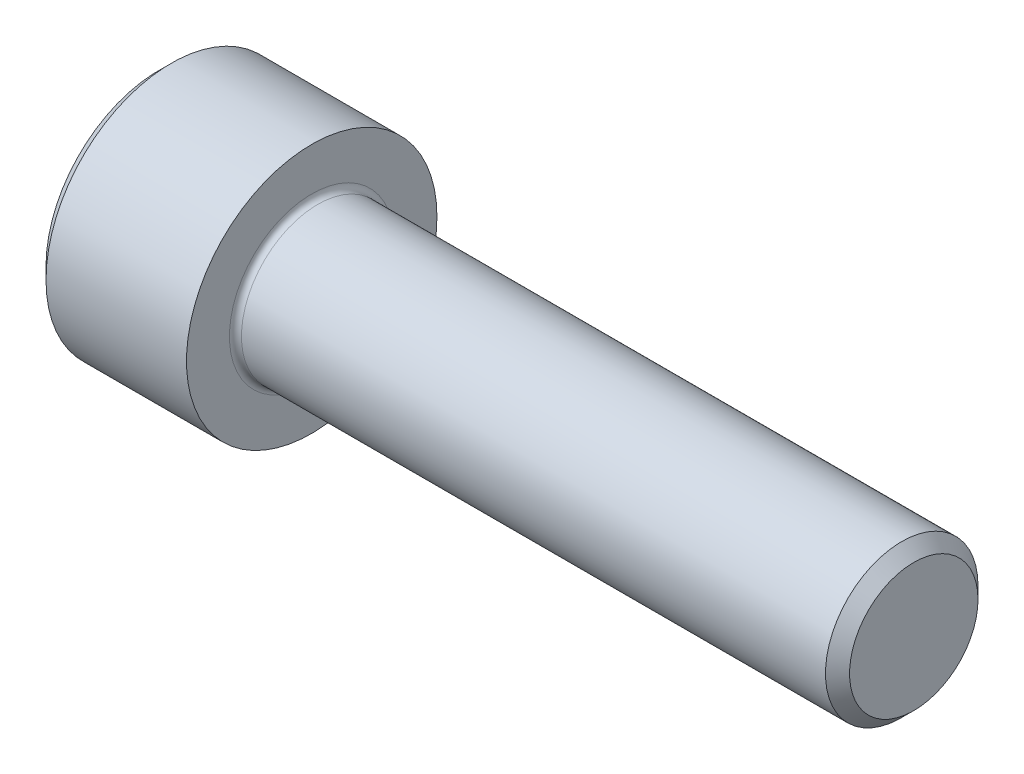
from build123d import *

# Parameters (mm, degrees)
HEX_START         = -3.217333
HEX_2_DEPTH       = 3.217333
CHAMFER1_SIZE     = 0.381
FILLET1_R         = 0.1905
SKETCH3_R         = 2.291358881
HEX_CHAMFER_DEPTH = 2.54
HEX_CHAMFER_DRAFT = 45


with BuildPart() as part:
    # Sketch1 → Body (revolve)
    with BuildSketch(Plane(origin=(0, 0, 0), x_dir=(1, 0, 0), z_dir=(0, 1, 0))):
        Polygon((0, 0), (0, 3.9624), (4.826, 3.9624), (4.826, 2.413), (23.876, 2.413), (23.876, 0), align=None)
    revolve(axis=Axis((23.876, 0, 0), (-1, 0, 0)))

    # Sketch2 → Hex 2 (cut)
    with BuildSketch(Plane.ZY.offset(HEX_START)):
        Polygon((-2.291358881, 0), (-1.14567944, -1.984375), (1.14567944, -1.984375), (2.291358881, 0), (1.14567944, 1.984375), (-1.14567944, 1.984375), align=None)
    extrude(amount=HEX_2_DEPTH, mode=Mode.SUBTRACT)

    # Chamfer1
    chamfer1_edges = [part.edges().sort_by_distance(p)[0] for p in [
        (0, 0, 3.9624),
        (23.876, 0, 2.413),
    ]]
    chamfer(chamfer1_edges, length=CHAMFER1_SIZE)

    # Fillet1
    fillet1_edges = [part.edges().sort_by_distance(p)[0] for p in [
        (4.826, 0, 2.413),
    ]]
    fillet(fillet1_edges, radius=FILLET1_R)


with BuildPart() as hex_chamfer_tool:
    # Sketch3 → Hex Chamfer (with draft: the straight prism first)
    with BuildSketch(Plane(origin=(0, 0, 0), x_dir=(0, 0, -1), z_dir=(1, 0, 0))):
        Circle(SKETCH3_R)
    extrude(amount=HEX_CHAMFER_DEPTH)
    # Hex Chamfer: the draft: its side faces are tilted about the plane it starts from
    hex_chamfer_sides = [hex_chamfer_tool.faces().sort_by_distance(p)[0] for p in [
        (1.27, 0, 2.291358881),
    ]]
    draft(hex_chamfer_sides, Plane(origin=(0, 0, 0), x_dir=(0, 0, -1), z_dir=(1, 0, 0)), HEX_CHAMFER_DRAFT)


with BuildPart() as part_1:
    add(part.part)

    # Hex Chamfer: cut by hex_chamfer_tool
    add(hex_chamfer_tool.part, mode=Mode.SUBTRACT)


solid = part_1.part
